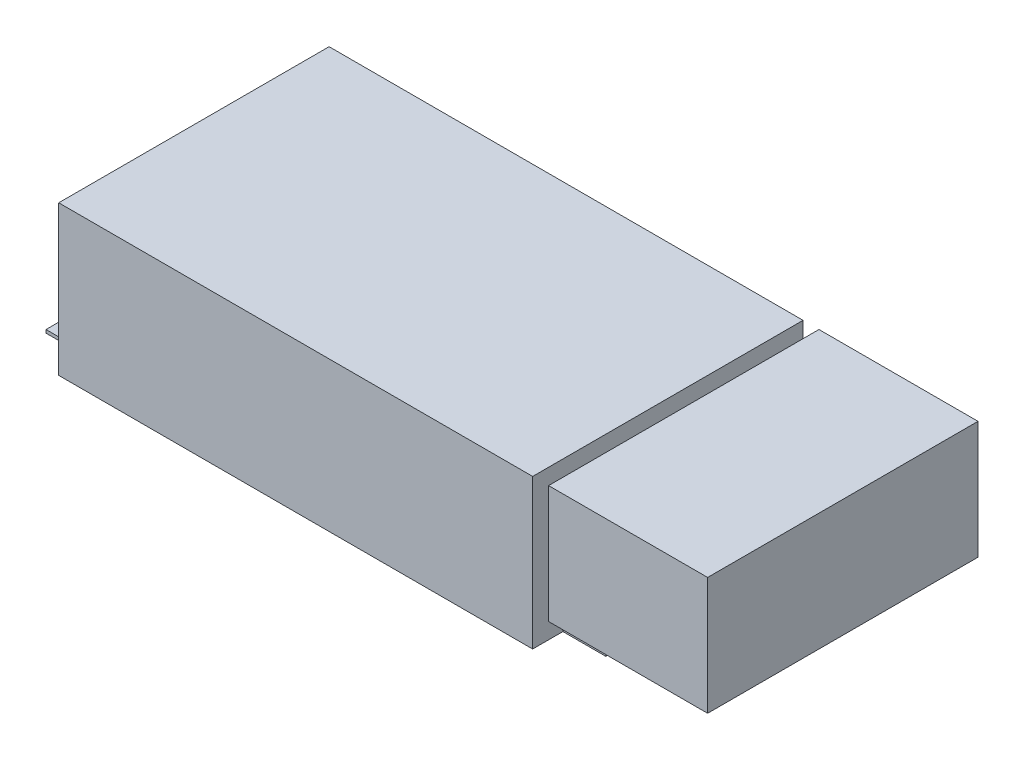
from build123d import *

# Parameters (mm, degrees)
SKETCH_1_W      = 149
SKETCH_1_H      = 85
EXTRUDE_1_DEPTH = 47
SKETCH_2_W      = 176
SKETCH_2_H      = 66
SKETCH_2_R      = 3.5
EXTRUDE_2_DEPTH = 1
EXTRUDE_START   = 5
SKETCH_3_W      = 85
SKETCH_3_H      = 37
EXTRUDE_3_DEPTH = 50


with BuildPart() as part:
    # Эскиз1 → Бобышка-Вытянуть1 (new body)
    with BuildSketch(Plane(origin=(0, 0, 0), x_dir=(1, 0, 0), z_dir=(0, 1, 0))):
        Rectangle(SKETCH_1_W, SKETCH_1_H)
    extrude(amount=EXTRUDE_1_DEPTH)

    # Эскиз2 → Бобышка-Вытянуть2 (add)
    with BuildSketch(Plane.XZ):
        Rectangle(SKETCH_2_W, SKETCH_2_H)
        with Locations((-81.5, 0)):
            Circle(SKETCH_2_R, mode=Mode.SUBTRACT)
        with Locations((81.5, 0)):
            Circle(SKETCH_2_R, mode=Mode.SUBTRACT)
        with BuildLine():
            Line((-78, 24), (-78, 18))
            ThreePointArc((-78, 18), (-81.5, 14.5), (-85, 18))
            Line((-85, 18), (-85, 24))
            ThreePointArc((-85, 24), (-81.5, 27.5), (-78, 24))
        make_face(mode=Mode.SUBTRACT)
        with BuildLine():
            Line((-78, -24), (-78, -18))
            ThreePointArc((-78, -18), (-81.5, -14.5), (-85, -18))
            Line((-85, -18), (-85, -24))
            ThreePointArc((-85, -24), (-81.5, -27.5), (-78, -24))
        make_face(mode=Mode.SUBTRACT)
        with BuildLine():
            Line((78, 24), (78, 18))
            ThreePointArc((78, 18), (81.5, 14.5), (85, 18))
            Line((85, 18), (85, 24))
            ThreePointArc((85, 24), (81.5, 27.5), (78, 24))
        make_face(mode=Mode.SUBTRACT)
        with BuildLine():
            Line((78, -24), (78, -18))
            ThreePointArc((78, -18), (81.5, -14.5), (85, -18))
            Line((85, -18), (85, -24))
            ThreePointArc((85, -24), (81.5, -27.5), (78, -24))
        make_face(mode=Mode.SUBTRACT)
    extrude(amount=-EXTRUDE_2_DEPTH)


with BuildPart() as body_2:
    # Эскиз3 → Бобышка-Вытянуть3 (new body)
    with BuildSketch(Plane(origin=(74.5, 0, 0), x_dir=(0, 0, -1), z_dir=(1, 0, 0)).offset(EXTRUDE_START)):
        with Locations((0, 28.5)):
            Rectangle(SKETCH_3_W, SKETCH_3_H)
    extrude(amount=EXTRUDE_3_DEPTH)


solid = Compound([part.part, body_2.part])
